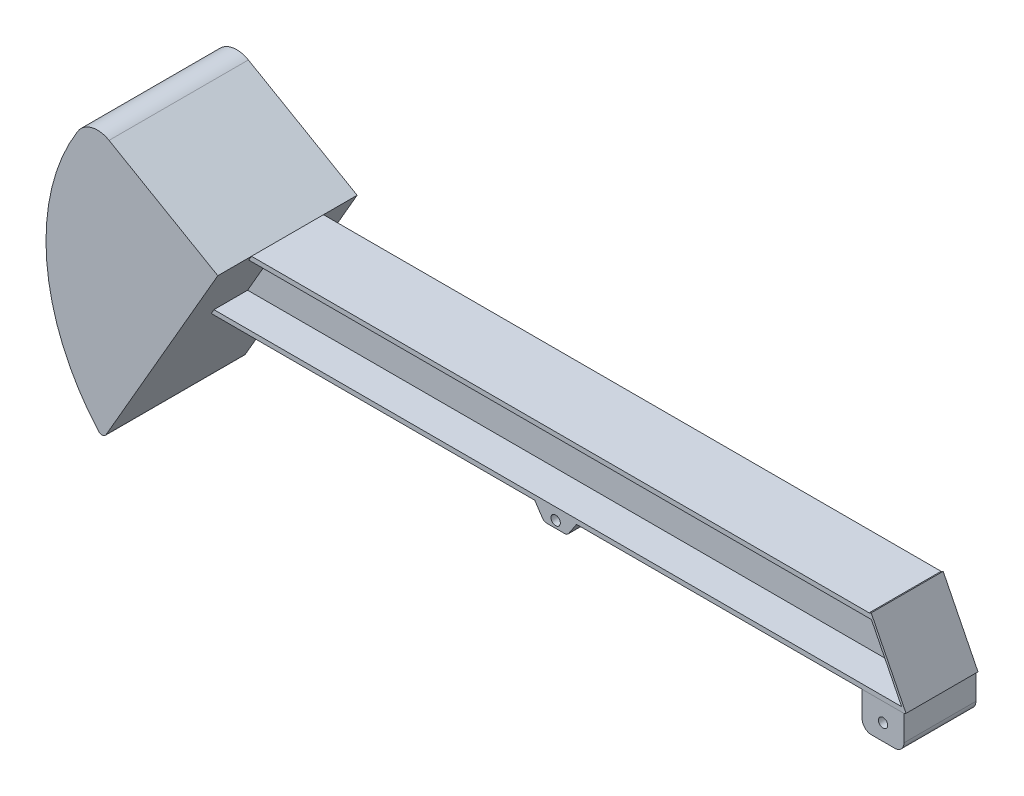
from build123d import *

# Parameters (mm, degrees)
BOSS_EXTRUDE1_DEPTH      = 77.5
FILLET1_R                = 10
SKETCH2_R                = 10
CUT_EXTRUDE1_DEPTH       = 156
BOSS_EXTRUDE2_DEPTH      = 750
BOSS_EXTRUDE2_DEPTH_BACK = 750
BOSS_EXTRUDE3_DEPTH      = 150
FILLET2_R                = 50
FILLET3_R                = 10
CUT_EXTRUDE2_DEPTH       = 150
SKETCH6_W                = 155
SKETCH6_H                = 167.705098313
BOSS_EXTRUDE4_DEPTH      = 5
SKETCH7_W                = 90
SKETCH7_H                = 75
BOSS_EXTRUDE5_DEPTH      = 155
FILLET4_R                = 20
SKETCH8_R                = 10
CUT_EXTRUDE3_DEPTH       = 228.5


with BuildPart() as part:
    # Sketch1 → Boss-Extrude1 (new body, symmetric)
    with BuildSketch(Plane.XY):
        Polygon((-45, 0), (45, 0), (25, -30), (-25, -30), align=None)
    extrude(amount=BOSS_EXTRUDE1_DEPTH, both=True)

    # Fillet1
    fillet1_edges = [part.edges().sort_by_distance(p)[0] for p in [
        (25, -30, 0),
        (-25, -30, 0),
    ]]
    fillet(fillet1_edges, radius=FILLET1_R)

    # Sketch2 → Cut-Extrude1 (cut, through all)
    with BuildSketch(Plane.XY.offset(77.5)):
        with Locations((0, -15)):
            Circle(SKETCH2_R)
    extrude(amount=-CUT_EXTRUDE1_DEPTH, mode=Mode.SUBTRACT)

    # Sketch3 → Boss-Extrude2 (add, two sides)
    with BuildSketch(Plane(origin=(0, 0, 0), x_dir=(0, 0, -1), z_dir=(1, 0, 0))) as boss_extrude2_sk:
        Polygon((-77.5, 0), (77.5, 0), (77.5, 10), (5, 10), (5, 140), (77.5, 140), (77.5, 150), (-77.5, 150), (-77.5, 140), (-5, 140), (-5, 10), (-77.5, 10), align=None)
    extrude(amount=BOSS_EXTRUDE2_DEPTH)
    extrude(boss_extrude2_sk.sketch, amount=-BOSS_EXTRUDE2_DEPTH_BACK)

    # Sketch4 → Boss-Extrude3 (add, symmetric)
    with BuildSketch(Plane.XY):
        with BuildLine():
            Line((-655, 150), (-928.797964194, 308.077328331))
            ThreePointArc((-928.797964194, 308.077328331), (-1024.547831071, 9.832015989), (-902.476115452, -278.641205623))
            Line((-902.476115452, -278.641205623), (-655, 150))
        make_face()
    extrude(amount=BOSS_EXTRUDE3_DEPTH, both=True)

    # Fillet2
    fillet2_edges = [part.edges().sort_by_distance(p)[0] for p in [
        (-928.797964194, 308.077328331, 0),
    ]]
    fillet(fillet2_edges, radius=FILLET2_R)

    # Fillet3
    fillet3_edges = [part.edges().sort_by_distance(p)[0] for p in [
        (-902.476115452, -278.641205623, 0),
    ]]
    fillet(fillet3_edges, radius=FILLET3_R)

    # Sketch5 → Cut-Extrude2 (cut, symmetric)
    with BuildSketch(Plane.XY.offset(5)):
        Polygon((750, 0), (675, 150), (750, 150), align=None)
    extrude(amount=CUT_EXTRUDE2_DEPTH, both=True, mode=Mode.SUBTRACT)

    # Sketch6 → Boss-Extrude4 (add)
    with BuildSketch(Plane(origin=(600, 300, 0), x_dir=(0, 0, -1), z_dir=(0.894427191, 0.447213595, 0))):
        with Locations((0, -251.557647469)):
            Rectangle(SKETCH6_W, SKETCH6_H)
    extrude(amount=BOSS_EXTRUDE4_DEPTH)


with BuildPart() as body_2:
    # Sketch7 → Boss-Extrude5 (new body)
    with BuildSketch(Plane.XY.offset(77.5)):
        with Locations((705, -37.5)):
            Rectangle(SKETCH7_W, SKETCH7_H)
    extrude(amount=-BOSS_EXTRUDE5_DEPTH)

    # Fillet4
    fillet4_edges = [body_2.edges().sort_by_distance(p)[0] for p in [
        (660, -75, 0),
        (750, -75, 0),
    ]]
    fillet(fillet4_edges, radius=FILLET4_R)

    # Sketch8 → Cut-Extrude3 (cut, through all)
    with BuildSketch(Plane.XY.offset(77.5)):
        with Locations((705, -40)):
            Circle(SKETCH8_R)
    extrude(amount=-CUT_EXTRUDE3_DEPTH, mode=Mode.SUBTRACT)


solid = Compound([part.part, body_2.part])
